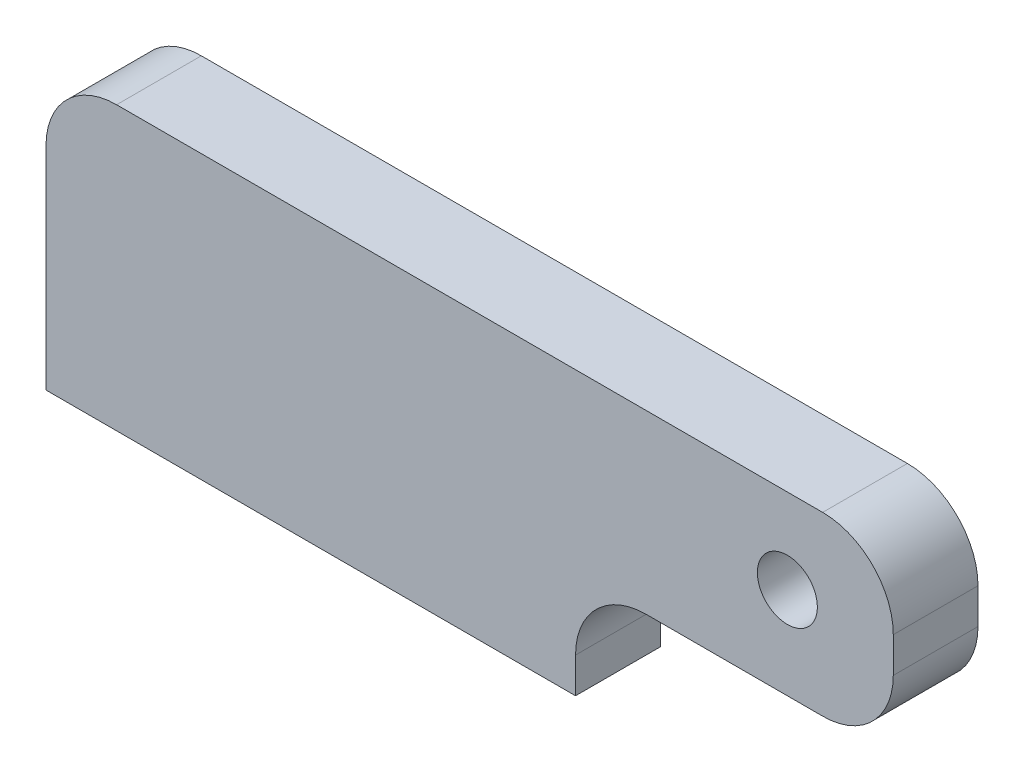
from build123d import *

# Parameters (mm, degrees)
EXTRUDE_1_DEPTH        = 6
HOLE_WIZARD_M6_1_D     = 5
HOLE_WIZARD_M6_1_DEPTH = 18
HOLE_WIZARD_M6_1_TIP   = 1.502151548
FILLET_1_R             = 10
HOLE_WIZARD_M10_1_D    = 8.5


with BuildPart() as part:
    # 草图1 → 凸台-拉伸1 (new body, symmetric)
    with BuildSketch(Plane.XY):
        Polygon((0, 0), (75, 0), (75, 15), (120, 15), (120, 40), (0, 40), align=None)
    extrude(amount=EXTRUDE_1_DEPTH, both=True)

    # M6 螺纹孔1
    with Locations(Plane(origin=(0, 0, 0), x_dir=(-1, 0, 0), z_dir=(0, -1, 0))):
        with Locations((-10, 0), (-65, 0)):
            Hole(HOLE_WIZARD_M6_1_D / 2, depth=HOLE_WIZARD_M6_1_DEPTH)
            with Locations((0, 0, -(HOLE_WIZARD_M6_1_DEPTH + HOLE_WIZARD_M6_1_TIP / 2))):  # 118° drill point
                Cone(0, HOLE_WIZARD_M6_1_D / 2, HOLE_WIZARD_M6_1_TIP, mode=Mode.SUBTRACT)

    # 圆角1
    fillet_1_edges = [part.edges().sort_by_distance(p)[0] for p in [
        (0, 40, 0),
        (120, 40, 0),
        (120, 15, 0),
        (75, 15, 0),
    ]]
    fillet(fillet_1_edges, radius=FILLET_1_R)

    # M10 螺纹孔1 (through all)
    with Locations(Plane.XY.offset(6)):
        with Locations((105, 28)):
            Hole(HOLE_WIZARD_M10_1_D / 2)


solid = part.part
